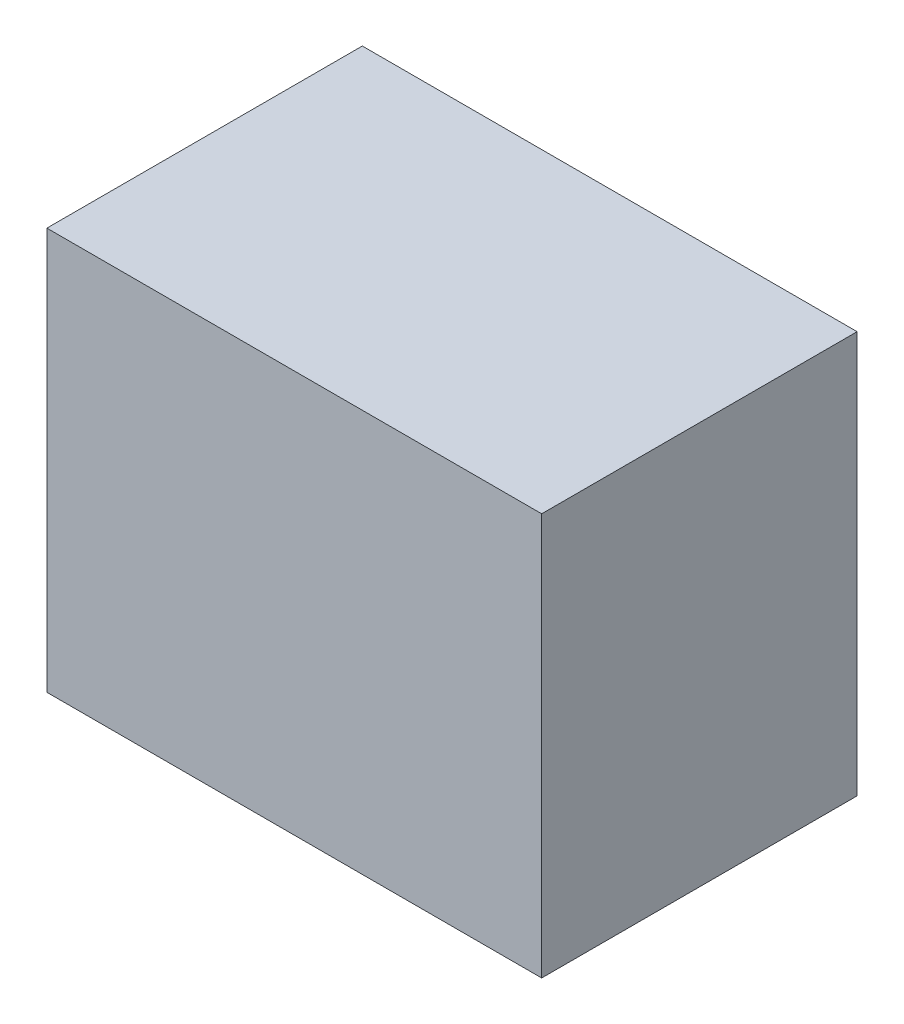
from build123d import *

# Parameters (mm, degrees)
SKETCH1_W           = 160
SKETCH1_H           = 130
BOSS_EXTRUDE1_DEPTH = 102


with BuildPart() as part:
    # Sketch1 → Boss-Extrude1 (new body)
    with BuildSketch(Plane.XY):
        Rectangle(SKETCH1_W, SKETCH1_H)
    extrude(amount=BOSS_EXTRUDE1_DEPTH)


solid = part.part
